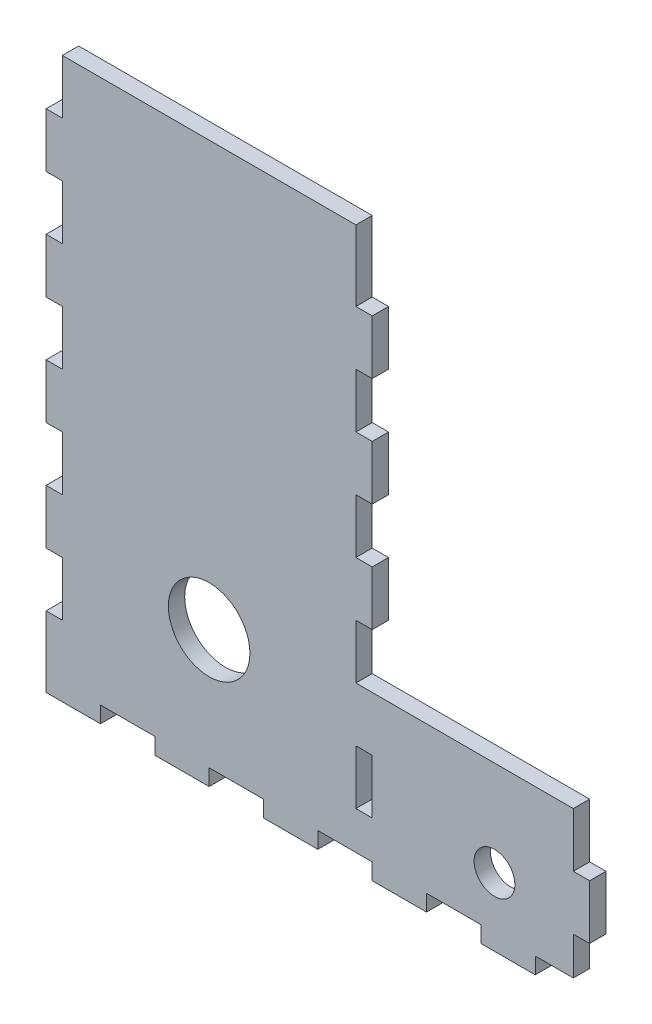
from build123d import *

# Parameters (mm, degrees)
BOSS_EXTRUDE1_DEPTH = 6
SKETCH2_W           = 20
SKETCH2_H           = 6
CUT_EXTRUDE1_DEPTH  = 7
LPATTERN1_COUNT     = 5
LPATTERN1_PITCH     = 40
SKETCH3_W           = 6
SKETCH3_H           = 20
CUT_EXTRUDE2_DEPTH  = 7
LPATTERN2_COUNT     = 5
LPATTERN2_PITCH     = 40
SKETCH4_W           = 6
SKETCH4_H           = 6
CUT_EXTRUDE3_DEPTH  = 10
SKETCH5_W           = 6
SKETCH5_H           = 20
CUT_EXTRUDE4_DEPTH  = 10
LPATTERN3_COUNT     = 2
LPATTERN3_PITCH     = 40
SKETCH7_W           = 6
SKETCH7_H           = 20
CUT_EXTRUDE5_DEPTH  = 10
LPATTERN4_COUNT     = 5
LPATTERN4_PITCH     = 40
SKETCH8_R           = 15
CUT_EXTRUDE6_DEPTH  = 10
SKETCH9_R           = 7.5
CUT_EXTRUDE7_DEPTH  = 7


with BuildPart() as part:
    # Sketch1 → Boss-Extrude1 (new body)
    with BuildSketch(Plane.XY):
        Polygon((-17.330934256, 199.427419355), (102.669065744, 199.427419355), (102.669065744, 53.427419355), (182.669065744, 53.427419355), (182.669065744, -6.572580645), (102.669065744, -6.572580645), (-17.330934256, -6.572580645), align=None)
    extrude(amount=BOSS_EXTRUDE1_DEPTH)

    # Sketch2 → Cut-Extrude1 (cut, through all)
    with BuildSketch(Plane.XY.offset(6)):
        with Locations((12.669065744, -3.572580645)):
            Rectangle(SKETCH2_W, SKETCH2_H)
    cut_extrude1 = extrude(amount=-CUT_EXTRUDE1_DEPTH, mode=Mode.SUBTRACT)

    # LPattern1: Cut-Extrude1 ×5
    with Locations(*[(i * LPATTERN1_PITCH, 0, 0) for i in range(1, LPATTERN1_COUNT)]):
        add(cut_extrude1, mode=Mode.SUBTRACT)

    # Sketch3 → Cut-Extrude2 (cut, through all)
    with BuildSketch(Plane.XY):
        with Locations((99.669065744, 23.427419355)):
            Rectangle(SKETCH3_W, SKETCH3_H)
    cut_extrude2 = extrude(amount=CUT_EXTRUDE2_DEPTH, mode=Mode.SUBTRACT)

    # LPattern2: Cut-Extrude2 ×5
    with Locations(*[(0, i * LPATTERN2_PITCH, 0) for i in range(1, LPATTERN2_COUNT)]):
        add(cut_extrude2, mode=Mode.SUBTRACT)

    # Sketch4 → Cut-Extrude3 (cut)
    with BuildSketch(Plane.XY.offset(6)):
        with Locations((99.669065744, 196.427419355)):
            Rectangle(SKETCH4_W, SKETCH4_H)
    extrude(amount=-CUT_EXTRUDE3_DEPTH, mode=Mode.SUBTRACT)

    # Sketch5 → Cut-Extrude4 (cut)
    with BuildSketch(Plane.XY.offset(6)):
        with Locations((179.669065744, 43.427419355)):
            Rectangle(SKETCH5_W, SKETCH5_H)
    cut_extrude4 = extrude(amount=-CUT_EXTRUDE4_DEPTH, mode=Mode.SUBTRACT)

    # LPattern3: Cut-Extrude4 ×2
    with Locations(*[(0, -i * LPATTERN3_PITCH, 0) for i in range(1, LPATTERN3_COUNT)]):
        add(cut_extrude4, mode=Mode.SUBTRACT)

    # Sketch7 → Cut-Extrude5 (cut)
    with BuildSketch(Plane.XY.offset(6)):
        with Locations((-14.330934256, 189.427419355)):
            Rectangle(SKETCH7_W, SKETCH7_H)
    cut_extrude5 = extrude(amount=-CUT_EXTRUDE5_DEPTH, mode=Mode.SUBTRACT)

    # LPattern4: Cut-Extrude5 ×5
    with Locations(*[(0, -i * LPATTERN4_PITCH, 0) for i in range(1, LPATTERN4_COUNT)]):
        add(cut_extrude5, mode=Mode.SUBTRACT)

    # Sketch8 → Cut-Extrude6 (cut)
    with BuildSketch(Plane(origin=(0, 0, 0), x_dir=(-1, 0, 0), z_dir=(0, 0, -1))):
        with Locations((-42.669065744, 43.427419355)):
            Circle(SKETCH8_R)
    extrude(amount=-CUT_EXTRUDE6_DEPTH, mode=Mode.SUBTRACT)

    # Sketch9 → Cut-Extrude7 (cut, through all)
    with BuildSketch(Plane(origin=(0, 0, 0), x_dir=(-1, 0, 0), z_dir=(0, 0, -1))):
        with Locations((-147.669065744, 18.427419355)):
            Circle(SKETCH9_R)
    extrude(amount=-CUT_EXTRUDE7_DEPTH, mode=Mode.SUBTRACT)


solid = part.part
